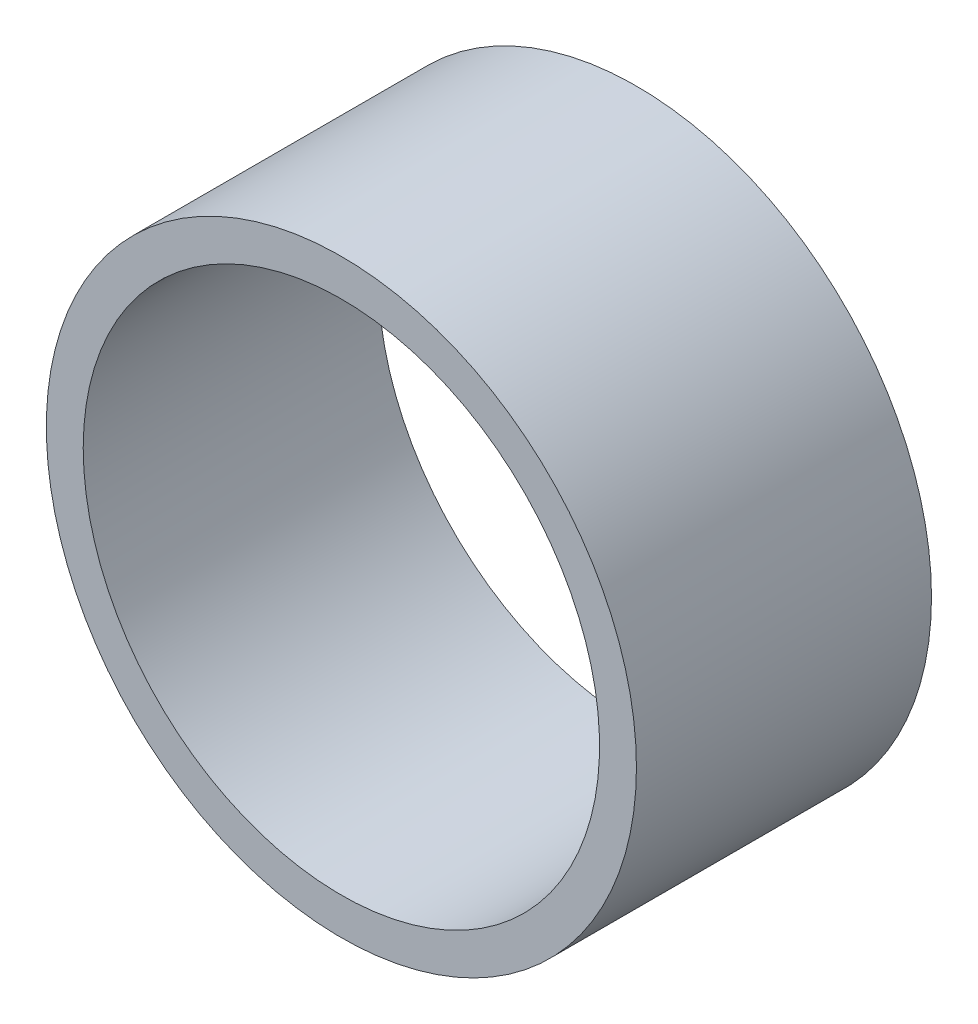
from build123d import *

# Parameters (mm, degrees)
SKETCH_1_R          = 16
EXTRUDE_1_DEPTH     = 16
SKETCH_2_R          = 14
CUT_EXTRUDE_1_DEPTH = 17


with BuildPart() as part:
    # Эскиз1 → Бобышка-Вытянуть1 (new body)
    with BuildSketch(Plane.XY):
        Circle(SKETCH_1_R)
    extrude(amount=EXTRUDE_1_DEPTH)

    # Эскиз2 → Вырез-Вытянуть1 (cut, through all)
    with BuildSketch(Plane(origin=(0, 0, 0), x_dir=(-1, 0, 0), z_dir=(0, 0, -1))):
        Circle(SKETCH_2_R)
    extrude(amount=-CUT_EXTRUDE_1_DEPTH, mode=Mode.SUBTRACT)


solid = part.part
